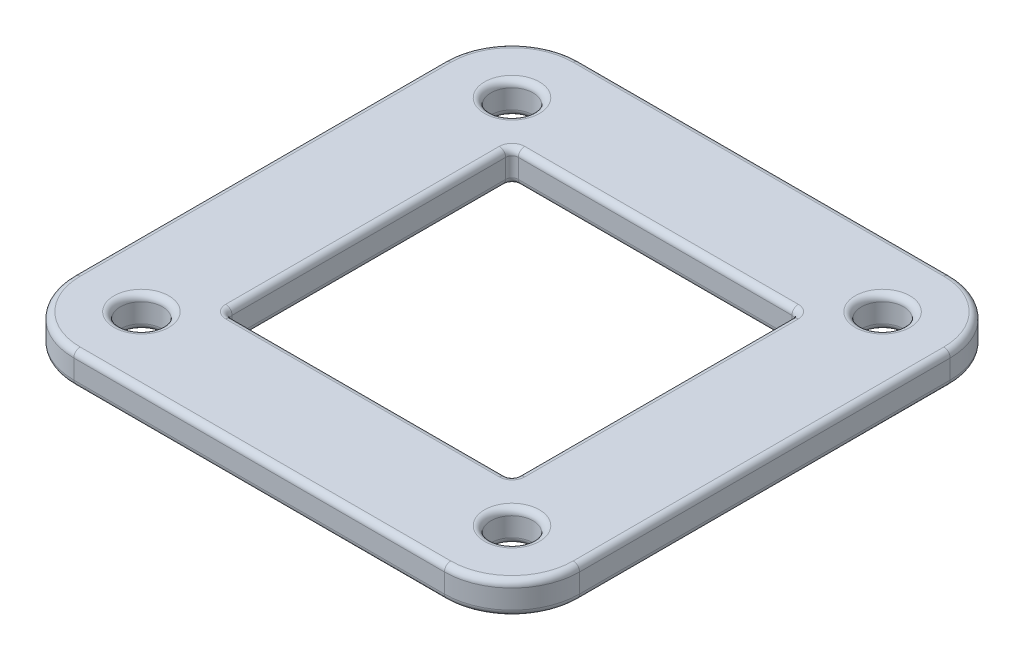
from build123d import *

# Parameters (mm, degrees)
MAIN_SKETCH_W        = 39.75
MAIN_SKETCH_H        = 39.75
MAIN_EXTRUDE_DEPTH   = 1.25
HOLE_CUTS_SKETCH_R   = 1.65625
HOLE_CUTS_SKETCH_W   = 22.5
HOLE_CUTS_SKETCH_H   = 22.5
HOLE_CUTS_DEPTH      = 2.25
HOLE_CUTS_DEPTH_BACK = 2.25
CORNER_FILLET_R      = 5.3125
SMALL_FILLET_R       = 0.5


with BuildPart() as part:
    # Main Sketch → Main Extrude (new body, symmetric)
    with BuildSketch(Plane(origin=(0, 0, 0), x_dir=(1, 0, 0), z_dir=(0, 1, 0))):
        Rectangle(MAIN_SKETCH_W, MAIN_SKETCH_H)
    extrude(amount=MAIN_EXTRUDE_DEPTH, both=True)

    # Hole Cuts Sketch → Hole Cuts (cut, two sides)
    with BuildSketch(Plane(origin=(0, 0, 0), x_dir=(1, 0, 0), z_dir=(0, 1, 0))) as hole_cuts_sk:
        with Locations((14.5625, 14.5625)):
            Circle(HOLE_CUTS_SKETCH_R)
        with Locations((14.5625, -14.5625)):
            Circle(HOLE_CUTS_SKETCH_R)
        with Locations((-14.5625, -14.5625)):
            Circle(HOLE_CUTS_SKETCH_R)
        with Locations((-14.5625, 14.5625)):
            Circle(HOLE_CUTS_SKETCH_R)
        Rectangle(HOLE_CUTS_SKETCH_W, HOLE_CUTS_SKETCH_H)
    extrude(amount=HOLE_CUTS_DEPTH, mode=Mode.SUBTRACT)
    extrude(hole_cuts_sk.sketch, amount=-HOLE_CUTS_DEPTH_BACK, mode=Mode.SUBTRACT)

    # Corner Fillet
    corner_fillet_edges = [part.edges().sort_by_distance(p)[0] for p in [
        (-19.875, 0, -19.875),
        (19.875, 0, -19.875),
        (19.875, 0, 19.875),
        (-19.875, 0, 19.875),
    ]]
    fillet(corner_fillet_edges, radius=CORNER_FILLET_R)

    # Small Fillet
    small_fillet_edges = [part.edges().sort_by_distance(p)[0] for p in [
        (-16.21875, -1.25, 14.5625),
        (-16.21875, 1.25, 14.5625),
        (12.90625, -1.25, 14.5625),
        (12.90625, 1.25, 14.5625),
        (12.90625, -1.25, -14.5625),
        (12.90625, 1.25, -14.5625),
        (-16.21875, -1.25, -14.5625),
        (-16.21875, 1.25, -14.5625),
        (-11.25, 0, 11.25),
        (-11.25, -1.25, 0),
        (-11.25, 0, -11.25),
        (0, -1.25, -11.25),
        (11.25, 0, -11.25),
        (11.25, -1.25, 0),
        (11.25, 0, 11.25),
        (0, -1.25, 11.25),
        (-11.25, 1.25, 0),
        (0, 1.25, 11.25),
        (11.25, 1.25, 0),
        (0, 1.25, -11.25),
        (-19.875, -1.25, 0),
        (-19.875, 1.25, 0),
        (0, -1.25, -19.875),
        (19.875, -1.25, 0),
        (0, -1.25, 19.875),
        (18.319004775, -1.25, 18.319004775),
        (18.319004775, -1.25, -18.319004775),
        (-18.319004775, -1.25, 18.319004775),
        (-18.319004775, -1.25, -18.319004775),
        (0, 1.25, -19.875),
        (0, 1.25, 19.875),
        (19.875, 1.25, 0),
        (18.319004775, 1.25, 18.319004775),
        (18.319004775, 1.25, -18.319004775),
        (-18.319004775, 1.25, 18.319004775),
        (-18.319004775, 1.25, -18.319004775),
    ]]
    fillet(small_fillet_edges, radius=SMALL_FILLET_R)


solid = part.part
